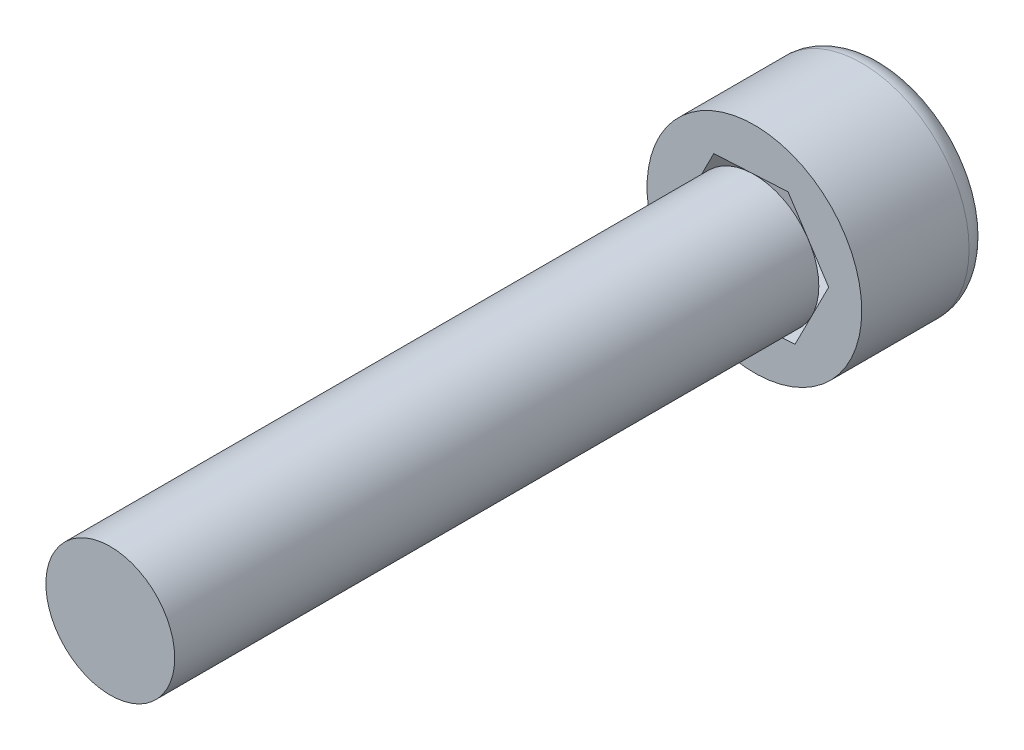
from build123d import *

# Parameters (mm, degrees)
SKETCH1_R           = 2.5
BOSS_EXTRUDE1_DEPTH = 3
SKETCH2_R           = 1.5
BOSS_EXTRUDE2_DEPTH = 15
CUT_EXTRUDE1_DEPTH  = 3
FILLET1_R           = 0.5


with BuildPart() as part:
    # Sketch1 → Boss-Extrude1 (new body)
    with BuildSketch(Plane.XY):
        Circle(SKETCH1_R)
    extrude(amount=BOSS_EXTRUDE1_DEPTH)

    # Sketch2 → Boss-Extrude2 (add)
    with BuildSketch(Plane.XY.offset(3)):
        Circle(SKETCH2_R)
    extrude(amount=BOSS_EXTRUDE2_DEPTH)

    # Sketch3 → Cut-Extrude1 (cut)
    with BuildSketch(Plane(origin=(0, 0, 0), x_dir=(-1, 0, 0), z_dir=(0, 0, -1))):
        Polygon((0.784462107, -1.544221229), (1.729565866, -0.092746502), (0.94510376, 1.451474727), (-0.784462107, 1.544221229), (-1.729565866, 0.092746502), (-0.94510376, -1.451474727), align=None)
    extrude(amount=-CUT_EXTRUDE1_DEPTH, mode=Mode.SUBTRACT)

    # Fillet1
    fillet1_edges = [part.edges().sort_by_distance(p)[0] for p in [
        (-2.5, 0, 0),
    ]]
    fillet(fillet1_edges, radius=FILLET1_R)


solid = part.part
